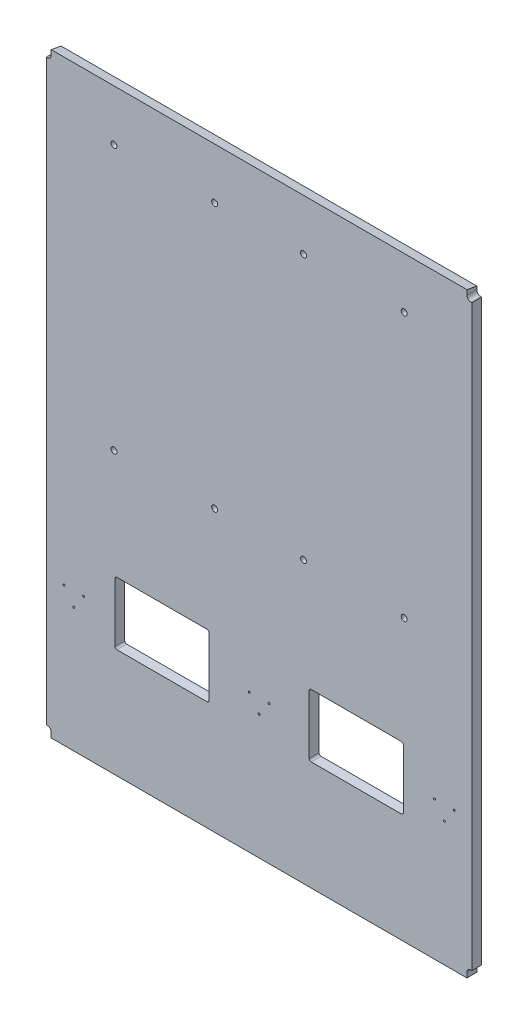
from build123d import *

# Parameters (mm, degrees)
SKETCH1_W               = 673.1
SKETCH1_H               = 965.2
BOSS_EXTRUDE1_DEPTH     = 7.9375
CUT_EXTRUDE1_DEPTH      = 1
CUT_EXTRUDE1_DEPTH_BACK = 16.875
CUT_EXTRUDE2_DEPTH      = 674.1
SKETCH4_W               = 7.9375
SKETCH4_H               = 936.625
BOSS_EXTRUDE2_DEPTH     = 15.875
FILLET1_R               = 6.35
SKETCH5_R               = 1.5875
CUT_EXTRUDE3_DEPTH      = 8
SKETCH6_R               = 4.826
CUT_EXTRUDE4_DEPTH      = 16.875


with BuildPart() as part:
    # Sketch1 → Boss-Extrude1 (new body, symmetric)
    with BuildSketch(Plane.XY):
        Rectangle(SKETCH1_W, SKETCH1_H)
    extrude(amount=BOSS_EXTRUDE1_DEPTH, both=True)

    # Sketch2 → Cut-Extrude1 (cut, two sides)
    with BuildSketch(Plane.XY.offset(7.9375)) as cut_extrude1_sk:
        with BuildLine():
            Line((-230.32810678, -204.086249688), (-84.27810678, -204.086249688))
            ThreePointArc((-84.27810678, -204.086249688), (-82.03304275, -205.016185658), (-81.10310678, -207.261249688))
            Line((-81.10310678, -207.261249688), (-81.10310678, -302.511249688))
            ThreePointArc((-81.10310678, -302.511249688), (-82.03304275, -304.756313718), (-84.27810678, -305.686249688))
            Line((-84.27810678, -305.686249688), (-230.32810678, -305.686249688))
            ThreePointArc((-230.32810678, -305.686249688), (-232.57317081, -304.756313718), (-233.50310678, -302.511249688))
            Line((-233.50310678, -302.511249688), (-233.50310678, -207.261249688))
            ThreePointArc((-233.50310678, -207.261249688), (-232.57317081, -205.016185658), (-230.32810678, -204.086249688))
        make_face()
        with BuildLine():
            Line((81.10310678, -207.261249688), (81.10310678, -302.511249688))
            ThreePointArc((81.10310678, -302.511249688), (82.03304275, -304.756313718), (84.27810678, -305.686249688))
            Line((84.27810678, -305.686249688), (230.32810678, -305.686249688))
            ThreePointArc((230.32810678, -305.686249688), (232.57317081, -304.756313718), (233.50310678, -302.511249688))
            Line((233.50310678, -302.511249688), (233.50310678, -207.261249688))
            ThreePointArc((233.50310678, -207.261249688), (232.57317081, -205.016185658), (230.32810678, -204.086249688))
            Line((230.32810678, -204.086249688), (84.27810678, -204.086249688))
            ThreePointArc((84.27810678, -204.086249688), (82.03304275, -205.016185658), (81.10310678, -207.261249688))
        make_face()
    extrude(amount=CUT_EXTRUDE1_DEPTH, mode=Mode.SUBTRACT)
    extrude(cut_extrude1_sk.sketch, amount=-CUT_EXTRUDE1_DEPTH_BACK, mode=Mode.SUBTRACT)

    # Sketch3 → Cut-Extrude2 (cut, through all)
    with BuildSketch(Plane(origin=(336.55, 0, 0), x_dir=(0, 0, -1), z_dir=(1, 0, 0))):
        Polygon((-7.9375, 482.6), (7.9375, 479.800809181), (7.9375, 482.6), align=None)
    extrude(amount=-CUT_EXTRUDE2_DEPTH, mode=Mode.SUBTRACT)

    # Sketch4 → Boss-Extrude2 (add)
    with BuildSketch(Plane.XY.offset(7.9375)):
        with Locations((-340.51875, 0)):
            Rectangle(SKETCH4_W, SKETCH4_H)
        with Locations((340.51875, 0)):
            Rectangle(SKETCH4_W, SKETCH4_H)
    extrude(amount=-BOSS_EXTRUDE2_DEPTH)

    # Fillet1
    fillet1_edges = [part.edges().sort_by_distance(p)[0] for p in [
        (-336.55, -468.3125, 0),
        (-336.55, 468.3125, 0),
        (336.55, 468.3125, 0),
        (336.55, -468.3125, 0),
    ]]
    fillet(fillet1_edges, radius=FILLET1_R)

    # Sketch5 → Cut-Extrude3 (cut)
    with BuildSketch(Plane.XY.offset(7.9375)):
        with Locations((-316, -257.871720704)):
            Circle(SKETCH5_R)
        with Locations((-284, -257.871720704)):
            Circle(SKETCH5_R)
        with Locations((-300, -280.871720704)):
            Circle(SKETCH5_R)
        with Locations((-16, -257.871720704)):
            Circle(SKETCH5_R)
        with Locations((16, -257.871720704)):
            Circle(SKETCH5_R)
        with Locations((0, -280.871720704)):
            Circle(SKETCH5_R)
        with Locations((284, -257.871720704)):
            Circle(SKETCH5_R)
        with Locations((300, -280.871720704)):
            Circle(SKETCH5_R)
        with Locations((316, -257.871720704)):
            Circle(SKETCH5_R)
    extrude(amount=-CUT_EXTRUDE3_DEPTH, mode=Mode.SUBTRACT)

    # Sketch6 → Cut-Extrude4 (cut, through all)
    with BuildSketch(Plane(origin=(0, 0, -7.9375), x_dir=(-1, 0, 0), z_dir=(0, 0, -1))):
        with Locations((-234.95, 400.05)):
            Circle(SKETCH6_R)
        with Locations((-71.966666709, 400.05)):
            Circle(SKETCH6_R)
        with Locations((71.966666709, 400.05)):
            Circle(SKETCH6_R)
        with Locations((234.95, 400.05)):
            Circle(SKETCH6_R)
        with Locations((-234.95, -28.575)):
            Circle(SKETCH6_R)
        with Locations((-71.966666709, -28.575)):
            Circle(SKETCH6_R)
        with Locations((71.966666709, -28.575)):
            Circle(SKETCH6_R)
        with Locations((234.95, -28.575)):
            Circle(SKETCH6_R)
    extrude(amount=-CUT_EXTRUDE4_DEPTH, mode=Mode.SUBTRACT)


solid = part.part
